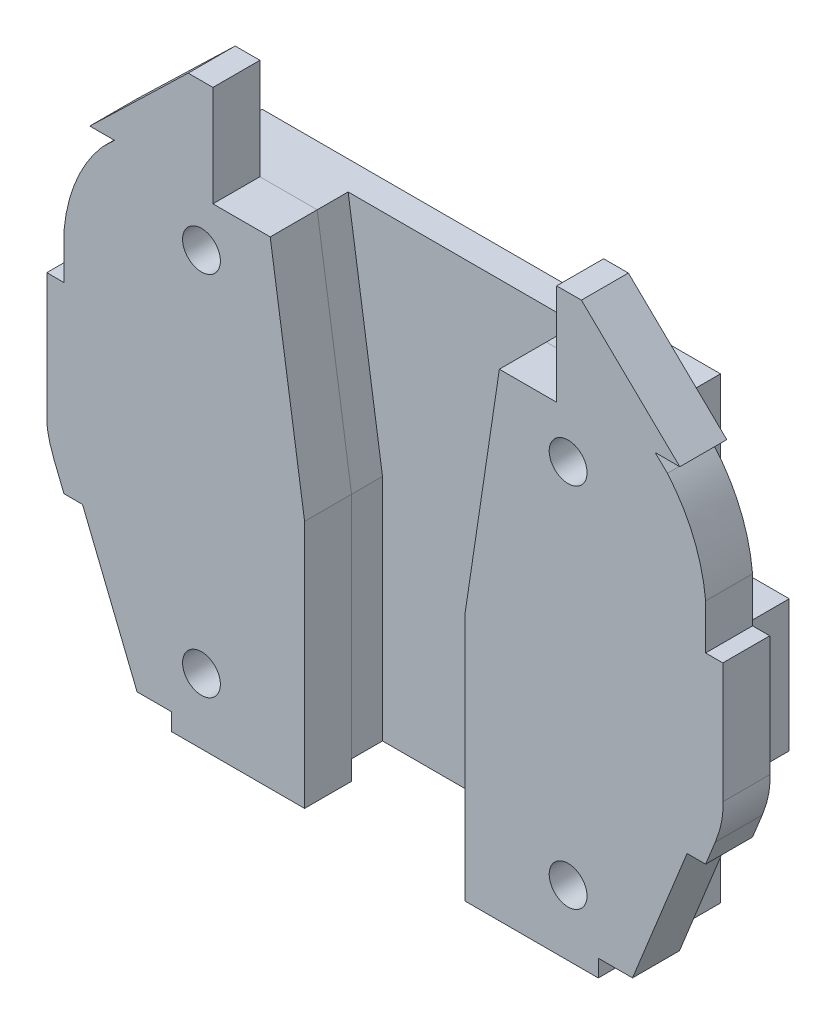
from build123d import *

# Parameters (mm, degrees)
SKETCH1_W                 = 40
SKETCH1_H                 = 40
BOSS_EXTRUDE1_DEPTH       = 5.2
SKETCH2_W                 = 40
SKETCH2_H                 = 11.5
BOSS_EXTRUDE2_DEPTH       = 6
SKETCH3_R                 = 1.6
CUT_EXTRUDE1_DEPTH        = 37.483333333
SKETCH4_R                 = 1.65
CUT_EXTRUDE2_DEPTH        = 5.2
CUT_EXTRUDE3_DEPTH        = 3.3
LPATTERN1_COUNT           = 2
LPATTERN1_PITCH           = 32
LPATTERN2_COUNT           = 2
LPATTERN2_PITCH           = 32
LPATTERN2_COPY_1_SKETCH_R = 1.65
LPATTERN2_COPY_1_DEPTH    = 5.2
LPATTERN2_COPY_2_DEPTH    = 3.3
CUT_EXTRUDE4_DEPTH        = 2.7
SKETCH6_3_R               = 1.65
SKETCH6_3_W               = 7
SKETCH6_3_H               = 1.5
SKETCH6_3_W_2             = 1.5
SKETCH6_3_H_2             = 7.501154436
BOSS_EXTRUDE3_DEPTH       = 4.1


with BuildPart() as part:
    # Sketch1 → Boss-Extrude1 (new body)
    with BuildSketch(Plane.XY):
        with Locations((21, 22.483732861)):
            Rectangle(SKETCH1_W, SKETCH1_H)
    extrude(amount=BOSS_EXTRUDE1_DEPTH)

    # Sketch2 → Boss-Extrude2 (add)
    with BuildSketch(Plane.XY.offset(-6)):
        with Locations((21, 16.733732861)):
            Rectangle(SKETCH2_W, SKETCH2_H)
    extrude(amount=BOSS_EXTRUDE2_DEPTH)

    # Sketch3 → Cut-Extrude1 (cut)
    with BuildSketch(Plane.XZ.offset(-5.000399528)):
        with Locations((11, -2.906796507)):
            Circle(SKETCH3_R)
        with Locations((31, -2.906796507)):
            Circle(SKETCH3_R)
    extrude(amount=-CUT_EXTRUDE1_DEPTH, mode=Mode.SUBTRACT)

    # Sketch4 → Cut-Extrude2 (cut)
    with BuildSketch(Plane(origin=(0, 0, 0), x_dir=(-1, 0, 0), z_dir=(0, 0, -1))):
        with Locations((-5, 6.483732861)):
            Circle(SKETCH4_R)
    cut_extrude2 = extrude(amount=-CUT_EXTRUDE2_DEPTH, mode=Mode.SUBTRACT)

    # Sketch1_3 → Cut-Extrude3 (cut)
    with BuildSketch(Plane.XY):
        Polygon((2, 4.723517403), (5, 3.018732861), (8, 4.749885982), (8, 8.21757974), (5, 9.948732861), (2, 8.21757974), align=None)
    cut_extrude3 = extrude(amount=CUT_EXTRUDE3_DEPTH, mode=Mode.SUBTRACT)

    # LPattern1: Cut-Extrude2, Cut-Extrude3 ×2
    with Locations(*[(i * LPATTERN1_PITCH, 0, 0) for i in range(1, LPATTERN1_COUNT)]):
        add(cut_extrude2, mode=Mode.SUBTRACT)
        add(cut_extrude3, mode=Mode.SUBTRACT)

    # LPattern2: Cut-Extrude2, Cut-Extrude3 ×2
    with Locations(*[(0, i * LPATTERN2_PITCH, 0) for i in range(1, LPATTERN2_COUNT)]):
        add(cut_extrude2, mode=Mode.SUBTRACT)
        add(cut_extrude3, mode=Mode.SUBTRACT)

    # LPattern2 copy 1 sketch → LPattern2 copy 1 (cut)
    with BuildSketch(Plane(origin=(32, 32, 0), x_dir=(-1, 0, 0), z_dir=(0, 0, -1))):
        with Locations((-5, 6.483732861)):
            Circle(LPATTERN2_COPY_1_SKETCH_R)
    extrude(amount=-LPATTERN2_COPY_1_DEPTH, mode=Mode.SUBTRACT)

    # LPattern2 copy 2 sketch → LPattern2 copy 2 (cut)
    with BuildSketch(Plane(origin=(32, 32, 0), x_dir=(1, 0, 0), z_dir=(0, 0, 1))):
        Polygon((2, 4.723517403), (5, 3.018732861), (8, 4.749885982), (8, 8.21757974), (5, 9.948732861), (2, 8.21757974), align=None)
    extrude(amount=LPATTERN2_COPY_2_DEPTH, mode=Mode.SUBTRACT)

    # Sketch6 → Cut-Extrude4 (cut)
    with BuildSketch(Plane.XY.offset(5.2)):
        Polygon((14, 2.483732861), (14, 22.483732861), (11, 42.483732861), (31, 42.483732861), (28, 22.483732861), (28, 2.483732861), align=None)
    extrude(amount=-CUT_EXTRUDE4_DEPTH, mode=Mode.SUBTRACT)


with BuildPart() as body_2:
    # Sketch6_3 → Boss-Extrude3 (new body)
    with BuildSketch(Plane.XY.offset(5.2)):
        Polygon((12.5, 2.483732861), (14, 2.483732861), (14, 22.483732861), (11, 42.483732861), (6.000729911, 42.483732861), (4.500729911, 42.483732861), (1, 42.483732861), (1, 2.483732861), align=None)
        with Locations((5, 6.483732861)):
            Circle(SKETCH6_3_R, mode=Mode.SUBTRACT)
        with Locations((5, 38.483732861)):
            Circle(SKETCH6_3_R, mode=Mode.SUBTRACT)
        Polygon((14, 0.783732861), (14, 2.483732861), (12.5, 2.483732861), (12.5, 2.283732861), (9.368445839, 2.283732861), (9.368445839, 0.783732861), align=None)
        Polygon((29.5, 2.483732861), (28, 2.483732861), (28, 0.783732861), (32.631554161, 0.783732861), (32.631554161, 2.283732861), (29.5, 2.283732861), align=None)
        Polygon((28, 22.483732861), (28, 2.483732861), (29.5, 2.483732861), (41, 2.483732861), (41, 42.483732861), (37.499270089, 42.483732861), (35.999270089, 42.483732861), (31, 42.483732861), align=None)
        with Locations((37, 6.483732861)):
            Circle(SKETCH6_3_R, mode=Mode.SUBTRACT)
        with Locations((37, 38.483732861)):
            Circle(SKETCH6_3_R, mode=Mode.SUBTRACT)
        with BuildLine():
            Line((12.5, 2.283732861), (12.5, 2.483732861))
            Line((12.5, 2.483732861), (1, 2.483732861))
            Line((1, 2.483732861), (1, 42.483732861))
            Line((1, 42.483732861), (4.500729911, 42.483732861))
            Line((4.500729911, 42.483732861), (4.500729911, 49.783732861))
            Line((4.500729911, 49.783732861), (4.447434441, 49.783732861))
            Line((4.447434441, 49.783732861), (1.858608656, 47.283732861))
            Line((1.858608656, 47.283732861), (-2.591394921, 42.986414359))
            Line((-2.591394921, 42.986414359), (-3.662956957, 41.951618929))
            add(Edge.make_bspline(
                [(-7, 33.969294903), (-6.870140729, 35.427391096), (-6.161424767, 38.328027166), (-4.617817273, 40.853318284), (-3.662956957, 41.951618929)],
                knots=[0.006919491, 0.006919491, 0.006919491, 0.006919491, 0.500067263, 0.993215035, 0.993215035, 0.993215035, 0.993215035], degree=3))
            Line((-7, 33.969294903), (-7, 30.034310079))
            Line((-7, 30.034310079), (-7, 22.533155643))
            Line((-7, 22.533155643), (-7, 19.486513051))
            add(Edge.make_bspline(
                [(-6.453878909, 16.723606193), (-6.550035771, 16.961602777), (-6.732637504, 17.457071628), (-6.915191313, 18.140873432), (-6.997225272, 18.69458891), (-7.013036312, 19.085155681), (-7.01063743, 19.3023473), (-7.003738635, 19.426454967), (-7, 19.486513051)],
                knots=[0, 0, 0, 0, 0.253262039, 0.506524078, 0.759786116, 0.886417136, 0.949732645, 1.013048155, 1.013048155, 1.013048155, 1.013048155], degree=3))
            Line((-6.453878909, 16.723606193), (-5.382540429, 14.071950405))
            Line((-5.382540429, 14.071950405), (-2.849612404, 7.802733549))
            Line((-2.849612404, 7.802733549), (-0.619791386, 2.283732861))
            Line((-0.619791386, 2.283732861), (2.368445839, 2.283732861))
            Line((2.368445839, 2.283732861), (9.368445839, 2.283732861))
            Line((9.368445839, 2.283732861), (12.5, 2.283732861))
        make_face()
        with BuildLine():
            Line((41, 2.483732861), (29.5, 2.483732861))
            Line((29.5, 2.483732861), (29.5, 2.283732861))
            Line((29.5, 2.283732861), (32.631554161, 2.283732861))
            Line((32.631554161, 2.283732861), (39.631554161, 2.283732861))
            Line((39.631554161, 2.283732861), (42.619791386, 2.283732861))
            Line((42.619791386, 2.283732861), (44.849612404, 7.802733549))
            Line((44.849612404, 7.802733549), (47.382540429, 14.071950405))
            Line((47.382540429, 14.071950405), (48.453878909, 16.723606193))
            add(Edge.make_bspline(
                [(48.453878909, 16.723606193), (48.550035771, 16.961602777), (48.732637504, 17.457071628), (48.915191313, 18.140873432), (48.997225272, 18.69458891), (49.013036312, 19.085155681), (49.01063743, 19.3023473), (49.003738635, 19.426454967), (49, 19.486513051)],
                knots=[0, 0, 0, 0, 0.253262039, 0.506524078, 0.759786116, 0.886417136, 0.949732645, 1.013048155, 1.013048155, 1.013048155, 1.013048155], degree=3))
            Line((49, 19.486513051), (49, 22.533155643))
            Line((49, 22.533155643), (49, 30.034310079))
            Line((49, 30.034310079), (49, 33.969294903))
            add(Edge.make_bspline(
                [(49, 33.969294903), (48.870140729, 35.427391096), (48.161424767, 38.328027166), (46.617817273, 40.853318284), (45.662956957, 41.951618929)],
                knots=[0.006919491, 0.006919491, 0.006919491, 0.006919491, 0.500067263, 0.993215035, 0.993215035, 0.993215035, 0.993215035], degree=3))
            Line((45.662956957, 41.951618929), (44.591394921, 42.986414359))
            Line((44.591394921, 42.986414359), (40.141391344, 47.283732861))
            Line((40.141391344, 47.283732861), (37.552565559, 49.783732861))
            Line((37.552565559, 49.783732861), (37.499270089, 49.783732861))
            Line((37.499270089, 49.783732861), (37.499270089, 42.483732861))
            Line((37.499270089, 42.483732861), (41, 42.483732861))
            Line((41, 42.483732861), (41, 2.483732861))
        make_face()
        with Locations((5.868445839, 1.533732861)):
            Rectangle(SKETCH6_3_W, SKETCH6_3_H)
        Polygon((4.500729911, 42.483732861), (6.000729911, 42.483732861), (6.000729911, 51.283732861), (3.841395102, 51.283732861), (-0.300726153, 47.283732861), (1.858608656, 47.283732861), (4.447434441, 49.783732861), (4.500729911, 49.783732861), align=None)
        with Locations((36.131554161, 1.533732861)):
            Rectangle(SKETCH6_3_W, SKETCH6_3_H)
        Polygon((35.999270089, 51.283732861), (35.999270089, 42.483732861), (37.499270089, 42.483732861), (37.499270089, 49.783732861), (37.552565559, 49.783732861), (40.141391344, 47.283732861), (42.300726153, 47.283732861), (38.158604898, 51.283732861), align=None)
        Polygon((1.858608656, 47.283732861), (-0.300726153, 47.283732861), (-4.75072973, 42.986414359), (-2.591394921, 42.986414359), align=None)
        with BuildLine():
            Line((-7.844654691, 16.161696302), (-7.000342543, 14.071950405))
            Line((-7.000342543, 14.071950405), (-5.382540429, 14.071950405))
            Line((-5.382540429, 14.071950405), (-6.453878909, 16.723606193))
            add(Edge.make_bspline(
                [(-6.453878909, 16.723606193), (-6.550035771, 16.961602777), (-6.732637504, 17.457071628), (-6.915191313, 18.140873432), (-6.997225272, 18.69458891), (-7.013036312, 19.085155681), (-7.01063743, 19.3023473), (-7.003738635, 19.426454967), (-7, 19.486513051)],
                knots=[0, 0, 0, 0, 0.253262039, 0.506524078, 0.759786116, 0.886417136, 0.949732645, 1.013048155, 1.013048155, 1.013048155, 1.013048155], degree=3))
            Line((-7, 19.486513051), (-7, 22.533155643))
            Line((-7, 22.533155643), (-8.5, 22.533155643))
            Line((-8.5, 22.533155643), (-8.5, 19.533155643))
            add(Edge.make_bspline(
                [(-7.844654691, 16.161696302), (-7.855523466, 16.188597464), (-8.291591299, 17.277219009), (-8.572201451, 18.373298795), (-8.5, 19.533155643)],
                knots=[0, 0, 0, 0, 0.024714148, 1, 1, 1, 1], degree=3))
        make_face()
        Polygon((46.75072973, 42.986414359), (42.300726153, 47.283732861), (40.141391344, 47.283732861), (44.591394921, 42.986414359), align=None)
        with BuildLine():
            Line((47.382540429, 14.071950405), (49.000342543, 14.071950405))
            Line((49.000342543, 14.071950405), (49.844654691, 16.161696302))
            add(Edge.make_bspline(
                [(49.844654691, 16.161696302), (49.855523466, 16.188597464), (50.291591299, 17.277219009), (50.572201451, 18.373298795), (50.5, 19.533155643)],
                knots=[0, 0, 0, 0, 0.024714148, 1, 1, 1, 1], degree=3))
            Line((50.5, 19.533155643), (50.5, 22.533155643))
            Line((50.5, 22.533155643), (49, 22.533155643))
            Line((49, 22.533155643), (49, 19.486513051))
            add(Edge.make_bspline(
                [(48.453878909, 16.723606193), (48.550035771, 16.961602777), (48.732637504, 17.457071628), (48.915191313, 18.140873432), (48.997225272, 18.69458891), (49.013036312, 19.085155681), (49.01063743, 19.3023473), (49.003738635, 19.426454967), (49, 19.486513051)],
                knots=[0, 0, 0, 0, 0.253262039, 0.506524078, 0.759786116, 0.886417136, 0.949732645, 1.013048155, 1.013048155, 1.013048155, 1.013048155], degree=3))
            Line((48.453878909, 16.723606193), (47.382540429, 14.071950405))
        make_face()
        with Locations((-7.75, 26.283732861)):
            Rectangle(SKETCH6_3_W_2, SKETCH6_3_H_2)
        with Locations((49.75, 26.283732861)):
            Rectangle(SKETCH6_3_W_2, SKETCH6_3_H_2)
    extrude(amount=BOSS_EXTRUDE3_DEPTH)


solid = Compound([part.part, body_2.part])
